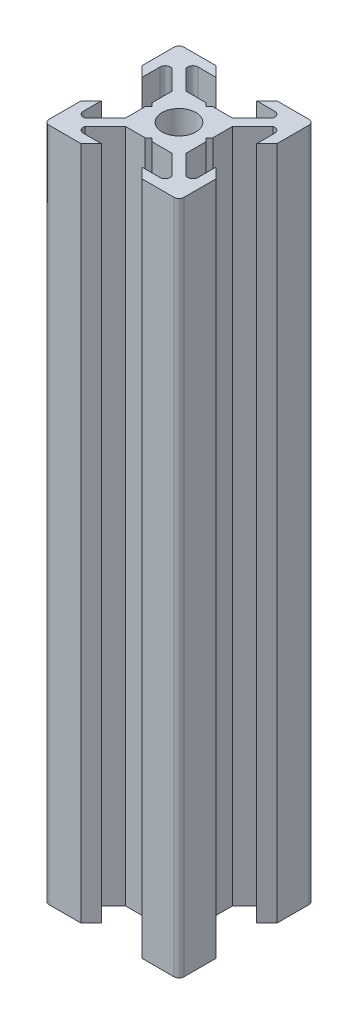
from build123d import *

# Parameters (mm, degrees)
ESQUISSE1_R      = 2.5
EXTRUSION1_DEPTH = 100
CONG_1_R         = 0.75


with BuildPart() as part:
    # Esquisse1 → Extrusion1 (new body)
    with BuildSketch(Plane(origin=(0, 0, 0), x_dir=(1, 0, 0), z_dir=(0, 1, 0))):
        Polygon((0, 4), (-0.5, 4.5), (-3.439339828, 4.5), (-6.439339828, 7.5), (-6.439339828, 8.5), (-3, 8.5), (-4.5, 10), (-10, 10), (-10, 4.5), (-8.5, 3), (-8.5, 6.439339828), (-7.5, 6.439339828), (-4.5, 3.439339828), (-4.5, 0.5), (-4, 0), (-4.5, -0.5), (-4.5, -3.439339828), (-7.5, -6.439339828), (-8.5, -6.439339828), (-8.5, -3), (-10, -4.5), (-10, -10), (-4.5, -10), (-3, -8.5), (-6.439339828, -8.5), (-6.439339828, -7.5), (-3.439339828, -4.5), (-0.5, -4.5), (0, -4), (0.5, -4.5), (3.439339828, -4.5), (6.439339828, -7.5), (6.439339828, -8.5), (3, -8.5), (4.5, -10), (10, -10), (10, -4.5), (8.5, -3), (8.5, -6.439339828), (7.5, -6.439339828), (4.5, -3.439339828), (4.5, -0.5), (4, 0), (4.5, 0.5), (4.5, 3.439339828), (7.5, 6.439339828), (8.5, 6.439339828), (8.5, 3), (10, 4.5), (10, 10), (4.5, 10), (3, 8.5), (6.439339828, 8.5), (6.439339828, 7.5), (3.439339828, 4.5), (0.5, 4.5), align=None)
        Circle(ESQUISSE1_R, mode=Mode.SUBTRACT)
    extrude(amount=EXTRUSION1_DEPTH)

    # Congé1
    cong_1_edges = [part.edges().sort_by_distance(p)[0] for p in [
        (6.439339828, 50, -8.5),
        (10, 50, -10),
        (8.5, 50, -6.439339828),
        (8.5, 50, 6.439339828),
        (10, 50, 10),
        (6.439339828, 50, 8.5),
        (-6.439339828, 50, 8.5),
        (-10, 50, 10),
        (-8.5, 50, 6.439339828),
        (-8.5, 50, -6.439339828),
        (-10, 50, -10),
        (-6.439339828, 50, -8.5),
    ]]
    fillet(cong_1_edges, radius=CONG_1_R)


solid = part.part
